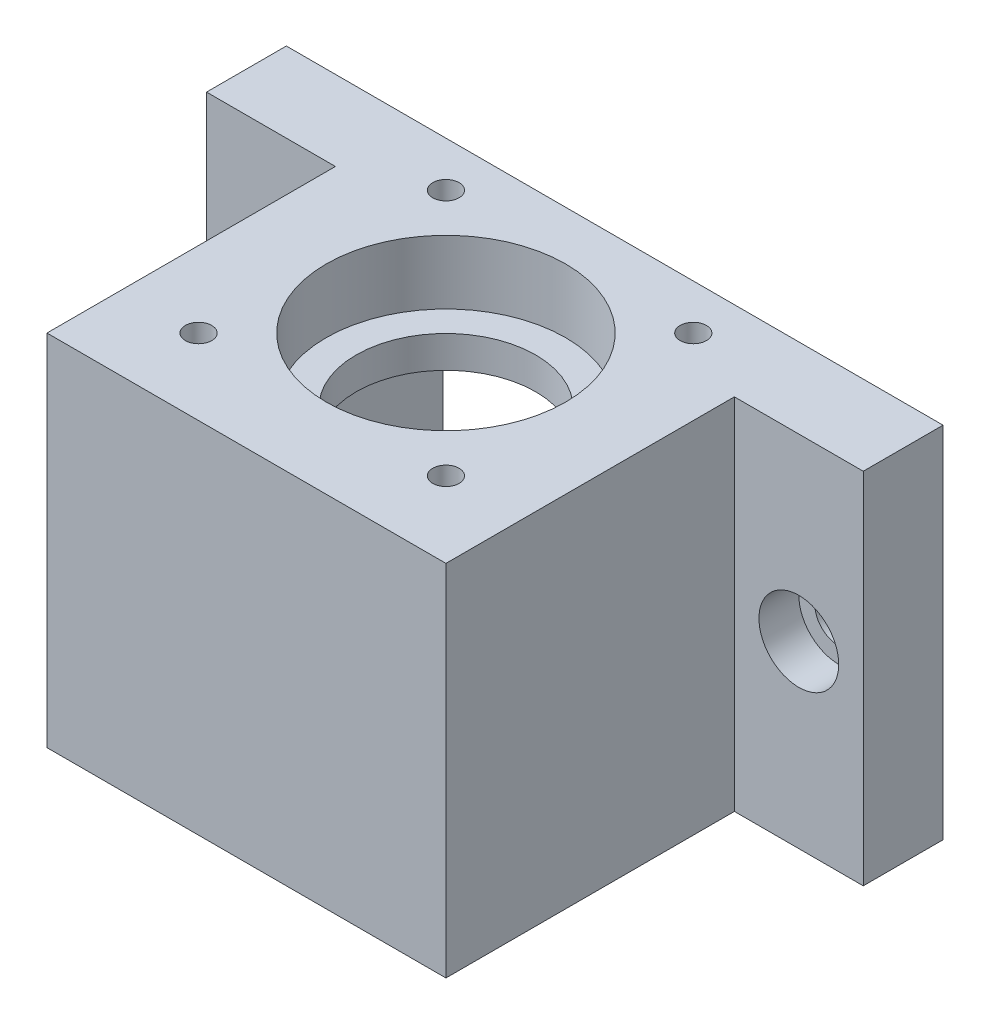
from build123d import *

# Parameters (mm, degrees)
EXTRUDE_1_DEPTH     = 45
CUT_EXTRUDE_1_DEPTH = 33
SKETCH_3_R          = 11.25
CUT_EXTRUDE_2_DEPTH = 13
SKETCH_4_R          = 1.65
CUT_EXTRUDE_3_DEPTH = 13
SKETCH_5_R          = 3
CUT_EXTRUDE_4_DEPTH = 11
SKETCH_6_R          = 5
CUT_EXTRUDE_5_DEPTH = 5
SKETCH_7_R          = 15
CUT_EXTRUDE_6_DEPTH = 8


with BuildPart() as part:
    # Эскиз1 → Бобышка-Вытянуть1 (new body)
    with BuildSketch(Plane(origin=(0, 0, 0), x_dir=(1, 0, 0), z_dir=(0, 1, 0))):
        Polygon((-21.15, 21.15), (21.15, 21.15), (41.15, 21.15), (41.15, 11.15), (25, 11.15), (25, -25), (-25, -25), (-25, 11.15), (-41.15, 11.15), (-41.15, 21.15), align=None)
    extrude(amount=EXTRUDE_1_DEPTH)

    # Эскиз2 → Вырез-Вытянуть1 (cut)
    with BuildSketch(Plane.XZ):
        Polygon((-21.5, 16.5), (-16.5, 21.5), (16.5, 21.5), (21.5, 16.5), (21.5, -21.5), (-21.5, -21.5), align=None)
    extrude(amount=-CUT_EXTRUDE_1_DEPTH, mode=Mode.SUBTRACT)

    # Эскиз3 → Вырез-Вытянуть2 (cut, through all)
    with BuildSketch(Plane.XZ.offset(-33)):
        Circle(SKETCH_3_R)
    extrude(amount=-CUT_EXTRUDE_2_DEPTH, mode=Mode.SUBTRACT)

    # Эскиз4 → Вырез-Вытянуть3 (cut, through all)
    with BuildSketch(Plane.XZ.offset(-33)):
        with Locations((-15.5, 15.5)):
            Circle(SKETCH_4_R)
        with Locations((15.5, 15.5)):
            Circle(SKETCH_4_R)
        with Locations((-15.5, -15.5)):
            Circle(SKETCH_4_R)
        with Locations((15.5, -15.5)):
            Circle(SKETCH_4_R)
    extrude(amount=-CUT_EXTRUDE_3_DEPTH, mode=Mode.SUBTRACT)

    # Эскиз5 → Вырез-Вытянуть4 (cut, through all)
    with BuildSketch(Plane.XY.offset(-11.15)):
        with Locations((-33.075, 22.5)):
            Circle(SKETCH_5_R)
        with Locations((33.075, 22.5)):
            Circle(SKETCH_5_R)
    extrude(amount=-CUT_EXTRUDE_4_DEPTH, mode=Mode.SUBTRACT)

    # Эскиз6 → Вырез-Вытянуть5 (cut)
    with BuildSketch(Plane.XY.offset(-11.15)):
        with Locations((-33.075, 22.5)):
            Circle(SKETCH_6_R)
        with Locations((33.075, 22.5)):
            Circle(SKETCH_6_R)
    extrude(amount=-CUT_EXTRUDE_5_DEPTH, mode=Mode.SUBTRACT)

    # Эскиз7 → Вырез-Вытянуть6 (cut)
    with BuildSketch(Plane(origin=(0, 45, 0), x_dir=(1, 0, 0), z_dir=(0, 1, 0))):
        Circle(SKETCH_7_R)
    extrude(amount=-CUT_EXTRUDE_6_DEPTH, mode=Mode.SUBTRACT)


solid = part.part
